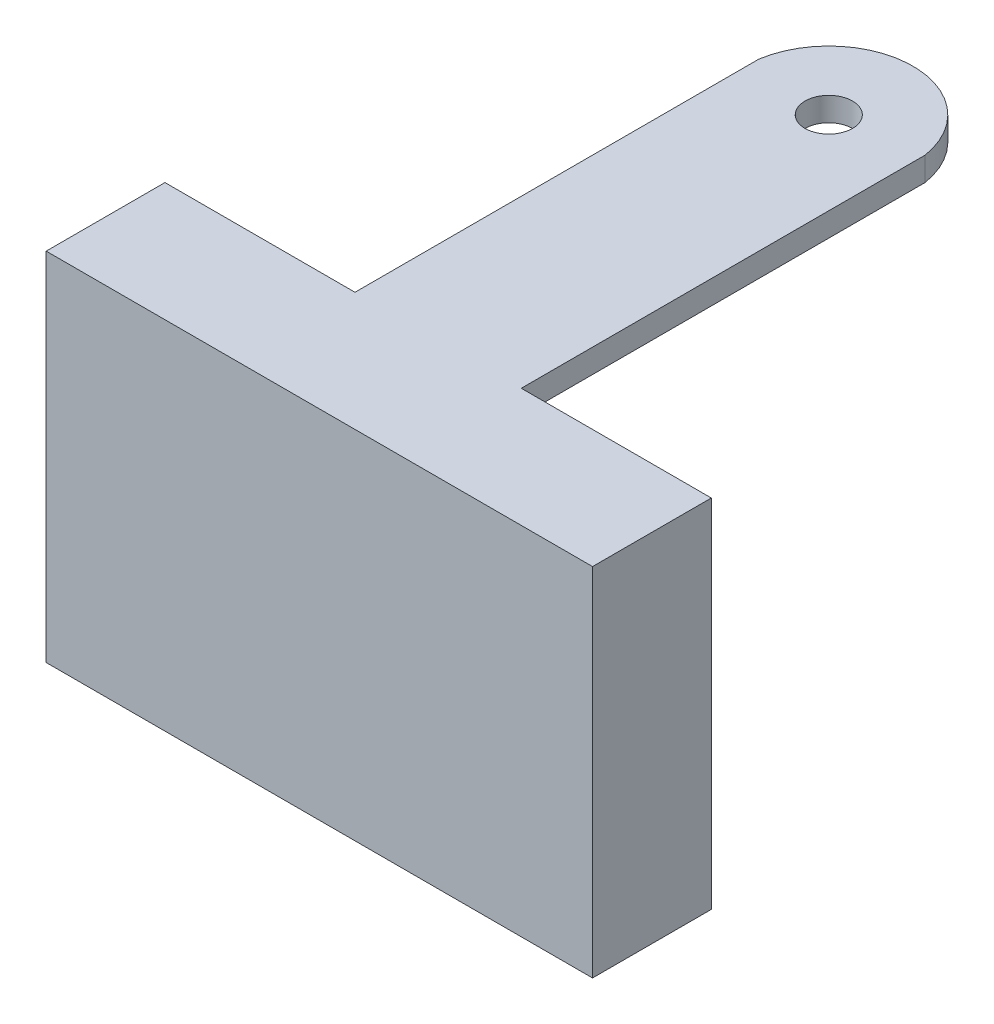
from build123d import *

# Parameters (mm, degrees)
SKETCH1_W           = 23
SKETCH1_H           = 5
BOSS_EXTRUDE1_DEPTH = 15
SKETCH3_R           = 1
BOSS_EXTRUDE4_DEPTH = 1


with BuildPart() as part:
    # Sketch1 → Boss-Extrude1 (new body)
    with BuildSketch(Plane(origin=(0, 0, 0), x_dir=(1, 0, 0), z_dir=(0, 1, 0))):
        Rectangle(SKETCH1_W, SKETCH1_H)
    extrude(amount=BOSS_EXTRUDE1_DEPTH)

    # Sketch3 → Boss-Extrude4 (add)
    with BuildSketch(Plane(origin=(0, 15, 0), x_dir=(1, 0, 0), z_dir=(0, 1, 0))):
        with BuildLine():
            Line((-3.5, 19.5), (-3.5, 2.5))
            Line((-3.5, 2.5), (3.5, 2.5))
            Line((3.5, 2.5), (3.5, 19.5))
            ThreePointArc((3.5, 19.5), (0, 22.488926095), (-3.5, 19.5))
        make_face()
        with Locations((0, 18.945232051)):
            Circle(SKETCH3_R, mode=Mode.SUBTRACT)
    extrude(amount=-BOSS_EXTRUDE4_DEPTH)


solid = part.part
